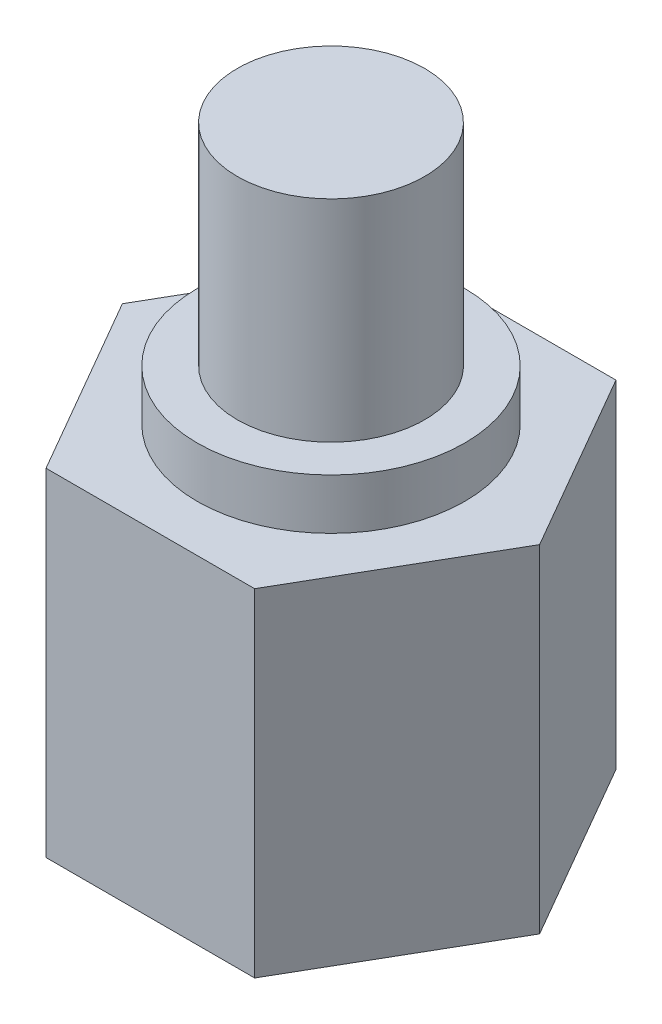
from build123d import *

# Parameters (mm, degrees)
BOSS_EXTRUDE1_DEPTH = 40
SKETCH2_R           = 15.875
BOSS_EXTRUDE2_DEPTH = 6
SKETCH3_R           = 11.1125
BOSS_EXTRUDE3_DEPTH = 25
SKETCH4_R           = 7.5
CUT_EXTRUDE1_DEPTH  = 25


with BuildPart() as part:
    # Sketch1 → Boss-Extrude1 (new body)
    with BuildSketch(Plane(origin=(0, 0, 0), x_dir=(1, 0, 0), z_dir=(0, 1, 0))):
        Polygon((24.75, 0), (12.375, 21.434128744), (-12.375, 21.434128744), (-24.75, 0), (-12.375, -21.434128744), (12.375, -21.434128744), align=None)
    extrude(amount=BOSS_EXTRUDE1_DEPTH)

    # Sketch4 → Cut-Extrude1 (cut)
    with BuildSketch(Plane.XZ):
        Circle(SKETCH4_R)
    extrude(amount=-CUT_EXTRUDE1_DEPTH, mode=Mode.SUBTRACT)


with BuildPart() as body_2:
    # Sketch2 → Boss-Extrude2 (new body)
    with BuildSketch(Plane(origin=(0, 40, 0), x_dir=(1, 0, 0), z_dir=(0, 1, 0))):
        Circle(SKETCH2_R)
    extrude(amount=BOSS_EXTRUDE2_DEPTH)


with BuildPart() as body_3:
    # Sketch3 → Boss-Extrude3 (new body)
    with BuildSketch(Plane(origin=(0, 46, 0), x_dir=(1, 0, 0), z_dir=(0, 1, 0))):
        Circle(SKETCH3_R)
    extrude(amount=BOSS_EXTRUDE3_DEPTH)


solid = Compound([part.part, body_2.part, body_3.part])
